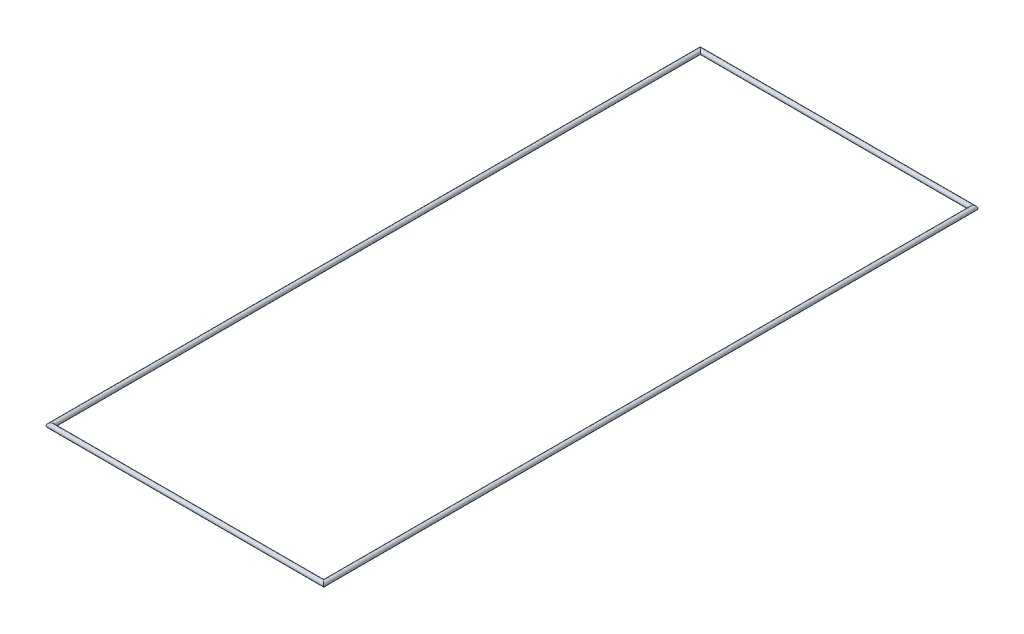
from build123d import *

# Parameters (mm, degrees)
SWEEP1_PROFILE_R = 0.5


with BuildPart() as part:
    # Sweep1: sweep along a path in Sketch1
    with BuildLine(Plane(origin=(0, 0, 0), x_dir=(1, 0, 0), z_dir=(0, 1, 0))) as sweep1_path:
        Line((-29, 54), (-29, -84))
        Line((-29, -84), (29, -84))
        Line((29, -84), (29, 54))
        Line((29, 54), (-29, 54))
    # Sweep1 profile (on start of the path) → Sweep1 (sweep)
    with BuildSketch(Plane(origin=(-29, 0, -54), x_dir=(1, 0, 0), z_dir=(0, 0, 1))):
        Circle(SWEEP1_PROFILE_R)
    sweep(path=sweep1_path.line, transition=Transition.RIGHT)


solid = part.part
